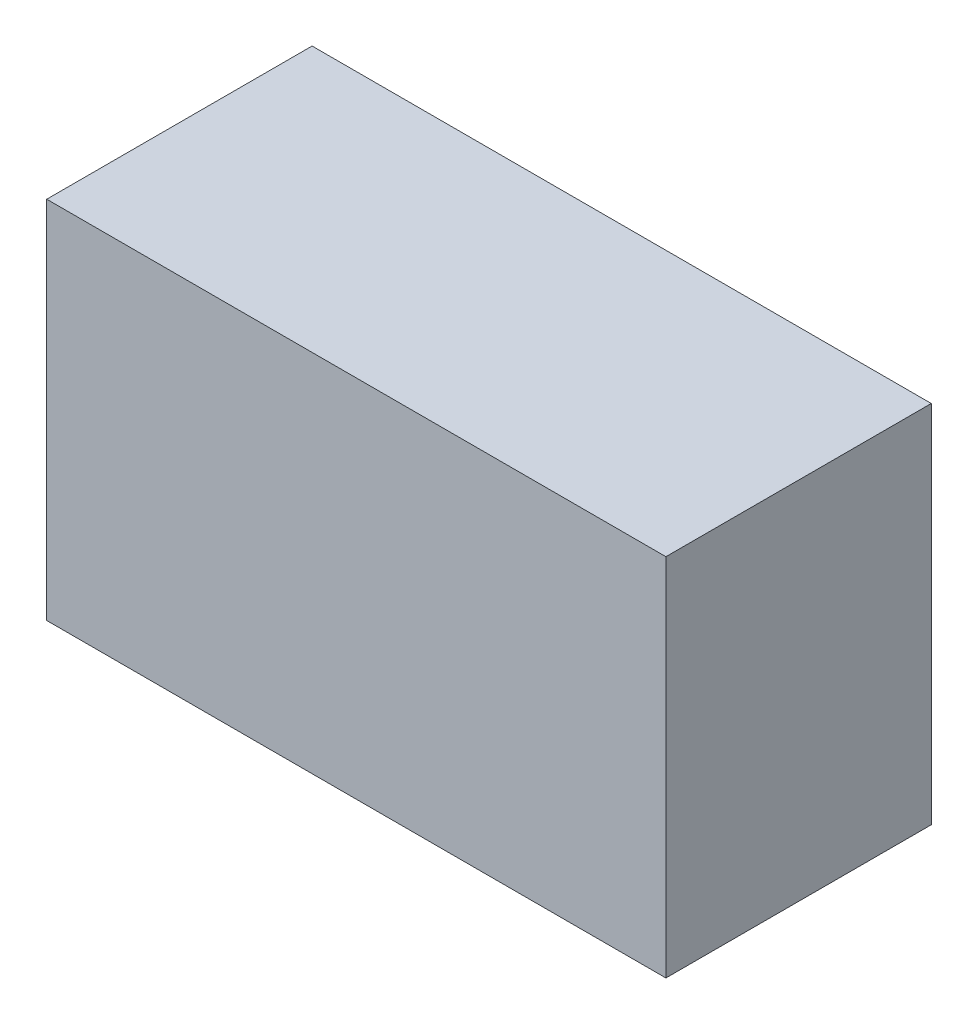
from build123d import *

# Parameters (mm, degrees)
SKETCH1_W           = 711.2
SKETCH1_H           = 419.1
BOSS_EXTRUDE1_DEPTH = 152.4


with BuildPart() as part:
    # Sketch1 → Boss-Extrude1 (new body, symmetric)
    with BuildSketch(Plane.XY):
        Rectangle(SKETCH1_W, SKETCH1_H)
    extrude(amount=BOSS_EXTRUDE1_DEPTH, both=True)


solid = part.part
